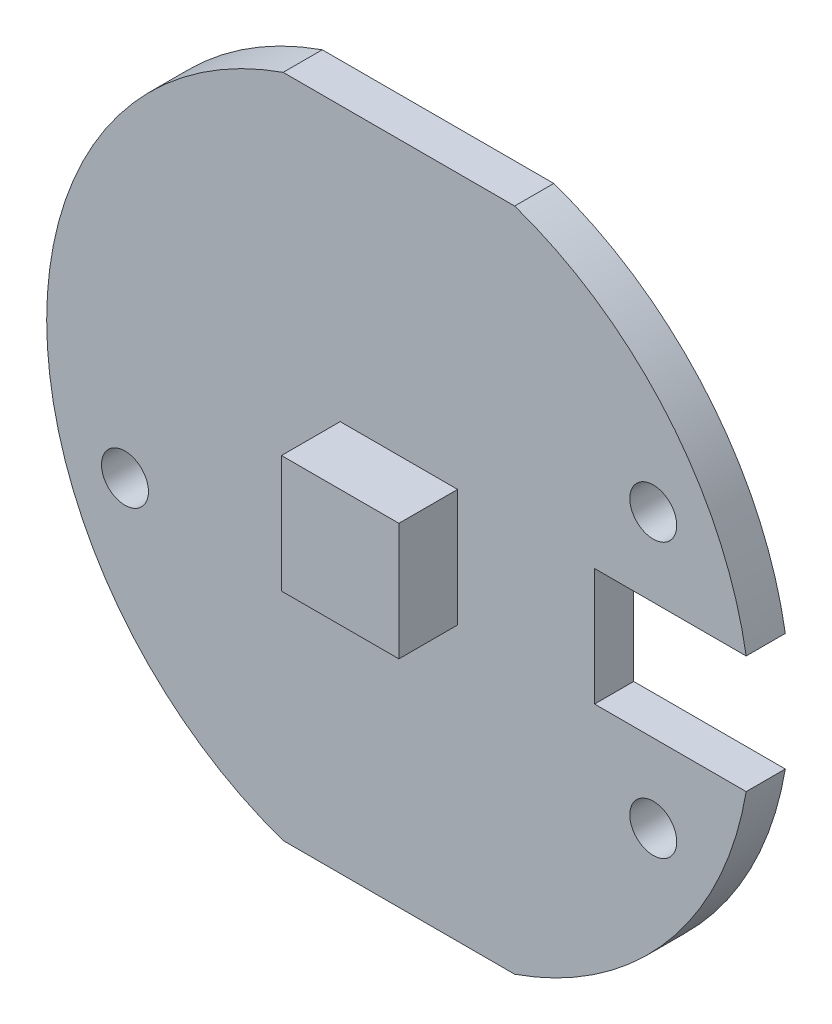
from build123d import *

# Parameters (mm, degrees)
SKETCH_1_R      = 0.6
EXTRUDE_1_DEPTH = 1
SKETCH_1_3_W    = 3
SKETCH_1_3_H    = 3
EXTRUDE_2_DEPTH = 1.5


with BuildPart() as part:
    # Sketch 1 → Extrude 1 (new body)
    with BuildSketch(Plane.XY):
        with BuildLine():
            Line((5, -1.5), (5, 1.5))
            Line((5, 1.5), (8.874119675, 1.5))
            ThreePointArc((8.874119675, 1.5), (6.873863542, 5.809475019), (2.958039892, 8.5))
            Line((2.958039892, 8.5), (-2.958039892, 8.5))
            ThreePointArc((-2.958039892, 8.5), (-9, 0), (-2.958039892, -8.5))
            Line((-2.958039892, -8.5), (2.958039892, -8.5))
            ThreePointArc((2.958039892, -8.5), (6.873863542, -5.809475019), (8.874119675, -1.5))
            Line((8.874119675, -1.5), (5, -1.5))
        make_face()
        with Locations((-7, -2.5)):
            Circle(SKETCH_1_R, mode=Mode.SUBTRACT)
        with Locations((6.5, -3.5)):
            Circle(SKETCH_1_R, mode=Mode.SUBTRACT)
        with Locations((6.5, 3.5)):
            Circle(SKETCH_1_R, mode=Mode.SUBTRACT)
    extrude(amount=-EXTRUDE_1_DEPTH)

    # Sketch 1_3 → Extrude 2 (add)
    with BuildSketch(Plane.XY):
        Rectangle(SKETCH_1_3_W, SKETCH_1_3_H)
    extrude(amount=EXTRUDE_2_DEPTH)


solid = part.part
